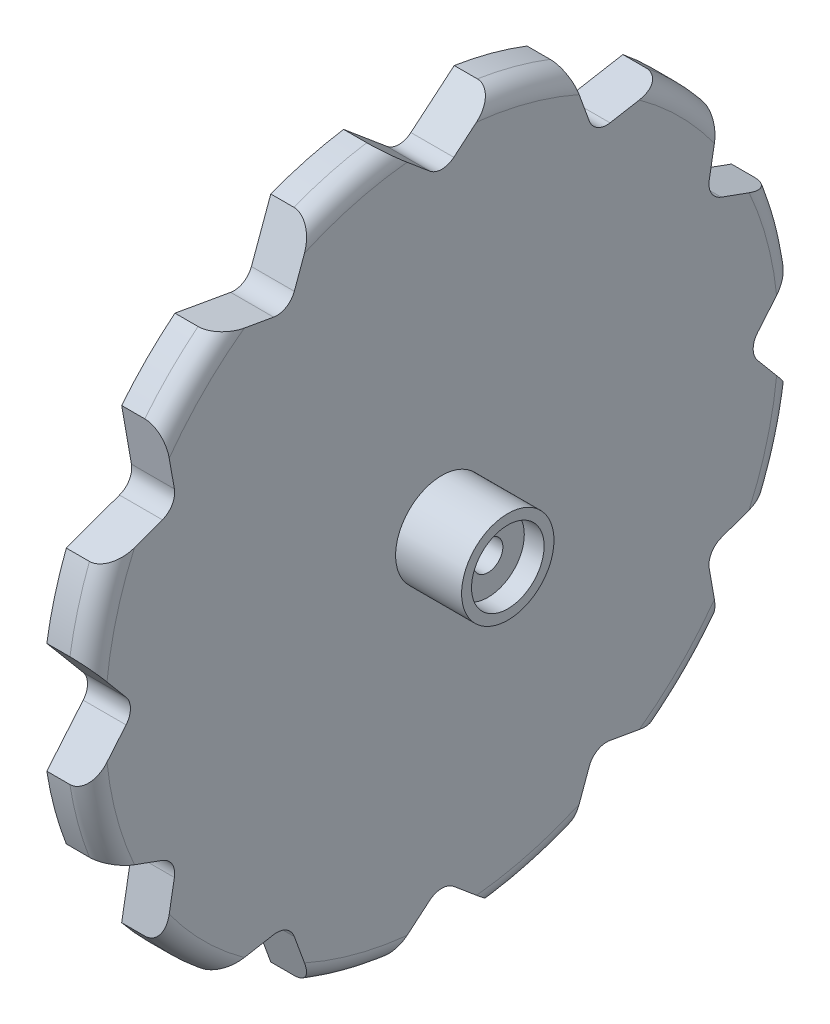
from build123d import *

# Parameters (mm, degrees)
BOSS_EXTRUDE1_DEPTH     = 6.5
SKETCH2_R               = 7
BOSS_EXTRUDE2_DEPTH     = 10
SKETCH3_R               = 5.5
CUT_EXTRUDE1_DEPTH      = 3
SKETCH4_R               = 2.25
CUT_EXTRUDE2_DEPTH      = 1
CUT_EXTRUDE2_DEPTH_BACK = 17.5
FILLET1_R               = 3


with BuildPart() as part:
    # Sketch1 → Boss-Extrude1 (new body)
    with BuildSketch(Plane(origin=(0, 0, 0), x_dir=(0, 0, -1), z_dir=(1, 0, 0))):
        with BuildLine():
            Line((1.815874997, 47.835924448), (8.381939498, 53.345506749))
            ThreePointArc((8.381939498, 53.345506749), (13.976228436, 52.15999462), (19.413780836, 50.389533771))
            Line((19.413780836, 50.389533771), (22.345368346, 42.335063284))
            ThreePointArc((22.345368346, 42.335063284), (23.5875, 40.854748424), (25.490556102, 40.519188287))
            Line((25.490556102, 40.519188287), (33.931725912, 42.007594273))
            ThreePointArc((33.931725912, 42.007594273), (38.183766184, 38.183766184), (42.007594273, 33.931725912))
            Line((42.007594273, 33.931725912), (40.519188287, 25.490556102))
            ThreePointArc((40.519188287, 25.490556102), (40.854748424, 23.5875), (42.335063284, 22.345368346))
            Line((42.335063284, 22.345368346), (50.389533771, 19.413780836))
            ThreePointArc((50.389533771, 19.413780836), (52.15999462, 13.976228436), (53.345506749, 8.381939498))
            Line((53.345506749, 8.381939498), (47.835924448, 1.815874997))
            ThreePointArc((47.835924448, 1.815874997), (47.175, 0), (47.835924448, -1.815874997))
            Line((47.835924448, -1.815874997), (53.345506749, -8.381939498))
            ThreePointArc((53.345506749, -8.381939498), (52.15999462, -13.976228436), (50.389533771, -19.413780836))
            Line((50.389533771, -19.413780836), (42.335063284, -22.345368346))
            ThreePointArc((42.335063284, -22.345368346), (40.854748424, -23.5875), (40.519188287, -25.490556102))
            Line((40.519188287, -25.490556102), (42.007594273, -33.931725912))
            ThreePointArc((42.007594273, -33.931725912), (38.183766184, -38.183766184), (33.931725912, -42.007594273))
            Line((33.931725912, -42.007594273), (25.490556102, -40.519188287))
            ThreePointArc((25.490556102, -40.519188287), (23.5875, -40.854748424), (22.345368346, -42.335063284))
            Line((22.345368346, -42.335063284), (19.413780836, -50.389533771))
            ThreePointArc((19.413780836, -50.389533771), (13.976228436, -52.15999462), (8.381939498, -53.345506749))
            Line((8.381939498, -53.345506749), (1.815874997, -47.835924448))
            ThreePointArc((1.815874997, -47.835924448), (0, -47.175), (-1.815874997, -47.835924448))
            Line((-1.815874997, -47.835924448), (-8.381939498, -53.345506749))
            ThreePointArc((-8.381939498, -53.345506749), (-13.976228436, -52.15999462), (-19.413780836, -50.389533771))
            Line((-19.413780836, -50.389533771), (-22.345368346, -42.335063284))
            ThreePointArc((-22.345368346, -42.335063284), (-23.5875, -40.854748424), (-25.490556102, -40.519188287))
            Line((-25.490556102, -40.519188287), (-33.931725912, -42.007594273))
            ThreePointArc((-33.931725912, -42.007594273), (-38.183766184, -38.183766184), (-42.007594273, -33.931725912))
            Line((-42.007594273, -33.931725912), (-40.519188287, -25.490556102))
            ThreePointArc((-40.519188287, -25.490556102), (-40.854748424, -23.5875), (-42.335063284, -22.345368346))
            Line((-42.335063284, -22.345368346), (-50.389533771, -19.413780836))
            ThreePointArc((-50.389533771, -19.413780836), (-52.15999462, -13.976228436), (-53.345506749, -8.381939498))
            Line((-53.345506749, -8.381939498), (-47.835924448, -1.815874997))
            ThreePointArc((-47.835924448, -1.815874997), (-47.175, 0), (-47.835924448, 1.815874997))
            Line((-47.835924448, 1.815874997), (-53.345506749, 8.381939498))
            ThreePointArc((-53.345506749, 8.381939498), (-52.15999462, 13.976228436), (-50.389533771, 19.413780836))
            Line((-50.389533771, 19.413780836), (-42.335063284, 22.345368346))
            ThreePointArc((-42.335063284, 22.345368346), (-40.854748424, 23.5875), (-40.519188287, 25.490556102))
            Line((-40.519188287, 25.490556102), (-42.007594273, 33.931725912))
            ThreePointArc((-42.007594273, 33.931725912), (-38.183766184, 38.183766184), (-33.931725912, 42.007594273))
            Line((-33.931725912, 42.007594273), (-25.490556102, 40.519188287))
            ThreePointArc((-25.490556102, 40.519188287), (-23.5875, 40.854748424), (-22.345368346, 42.335063284))
            Line((-22.345368346, 42.335063284), (-19.413780836, 50.389533771))
            ThreePointArc((-19.413780836, 50.389533771), (-13.976228436, 52.15999462), (-8.381939498, 53.345506749))
            Line((-8.381939498, 53.345506749), (-1.815874997, 47.835924448))
            ThreePointArc((-1.815874997, 47.835924448), (0, 47.175), (1.815874997, 47.835924448))
        make_face()
    extrude(amount=BOSS_EXTRUDE1_DEPTH)

    # Sketch2 → Boss-Extrude2 (add)
    with BuildSketch(Plane(origin=(6.5, 0, 0), x_dir=(0, 0, -1), z_dir=(1, 0, 0))):
        Circle(SKETCH2_R)
    extrude(amount=BOSS_EXTRUDE2_DEPTH)

    # Sketch3 → Cut-Extrude1 (cut)
    with BuildSketch(Plane(origin=(16.5, 0, 0), x_dir=(0, 0, -1), z_dir=(1, 0, 0))):
        Circle(SKETCH3_R)
    extrude(amount=-CUT_EXTRUDE1_DEPTH, mode=Mode.SUBTRACT)

    # Sketch4 → Cut-Extrude2 (cut, two sides)
    with BuildSketch(Plane.ZY) as cut_extrude2_sk:
        Circle(SKETCH4_R)
    extrude(amount=CUT_EXTRUDE2_DEPTH, mode=Mode.SUBTRACT)
    extrude(cut_extrude2_sk.sketch, amount=-CUT_EXTRUDE2_DEPTH_BACK, mode=Mode.SUBTRACT)

    # Fillet1
    fillet1_edges = [part.edges().sort_by_distance(p)[0] for p in [
        (6.5, -52.15999462, 13.976228436),
        (6.5, -52.15999462, -13.976228436),
        (6.5, 52.15999462, -13.976228436),
        (6.5, -38.183766184, -38.183766184),
        (6.5, -13.976228436, -52.15999462),
        (6.5, 13.976228436, -52.15999462),
        (6.5, 38.183766184, -38.183766184),
        (6.5, 52.15999462, 13.976228436),
        (6.5, 38.183766184, 38.183766184),
        (6.5, 13.976228436, 52.15999462),
        (6.5, -13.976228436, 52.15999462),
        (6.5, -38.183766184, 38.183766184),
    ]]
    fillet(fillet1_edges, radius=FILLET1_R)


solid = part.part
